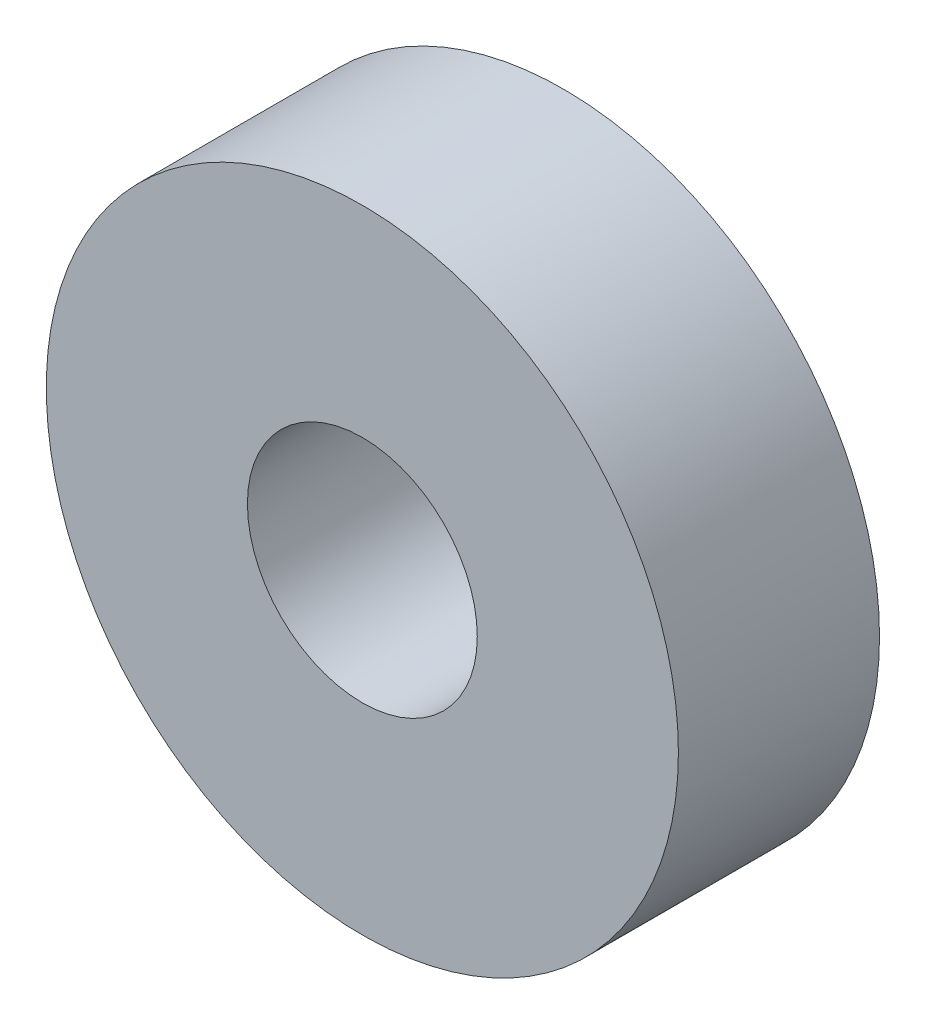
from build123d import *

# Parameters (mm, degrees)
SKETCH2_R           = 11
SKETCH2_R_2         = 4
BOSS_EXTRUDE1_DEPTH = 3.5


with BuildPart() as part:
    # Sketch2 → Boss-Extrude1 (new body, symmetric)
    with BuildSketch(Plane.XY):
        Circle(SKETCH2_R)
        Circle(SKETCH2_R_2, mode=Mode.SUBTRACT)
    extrude(amount=BOSS_EXTRUDE1_DEPTH, both=True)


solid = part.part
